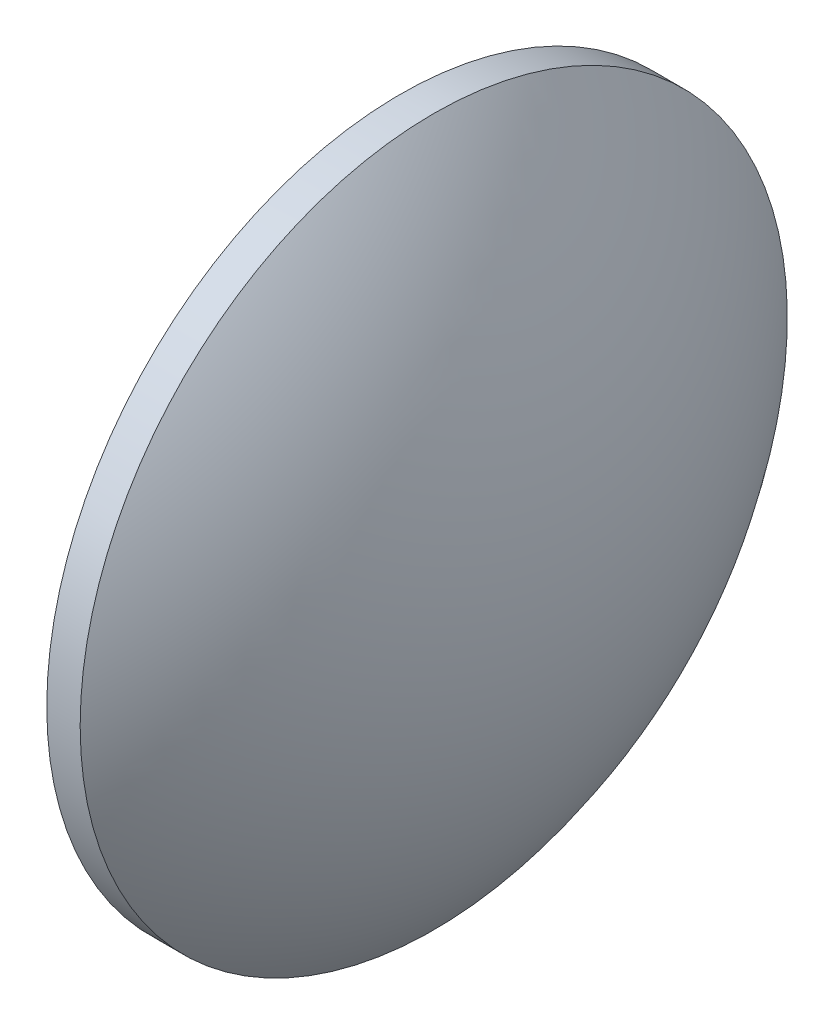
from build123d import *


with BuildPart() as part:
    # 草图1 → 旋转1 (revolve)
    with BuildSketch(Plane.XY):
        with BuildLine():
            Line((379.588643978, 55.922681591), (379.588643978, 73.922681591))
            Line((379.588643978, 73.922681591), (381.288643978, 73.922681591))
            ThreePointArc((381.288643978, 73.922681591), (385.968155535, 65.458010636), (387.588643978, 55.922681591))
            Line((387.588643978, 55.922681591), (379.588643978, 55.922681591))
        make_face()
    revolve(axis=Axis((374.010727679, 55.922681591, 0), (1, 0, 0)))


solid = part.part
